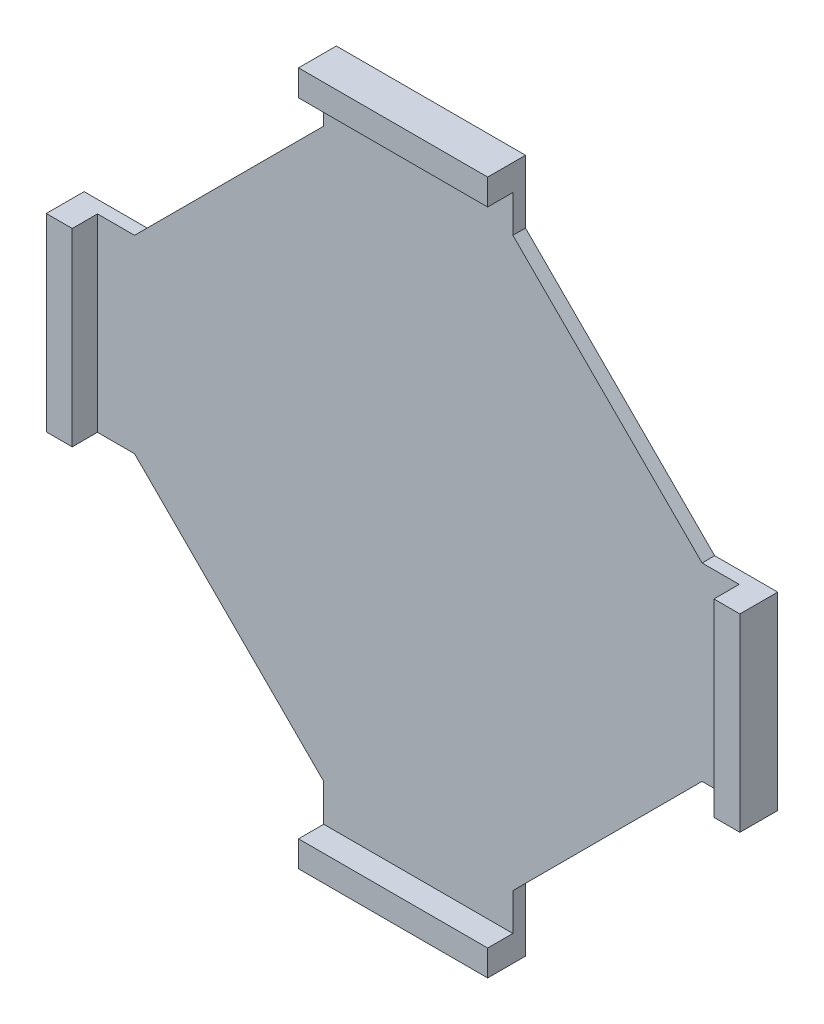
from build123d import *

# Parameters (mm, degrees)
BOSS_EXTRUDE1_DEPTH = 2.54
SKETCH2_W           = 38.1
SKETCH2_H           = 5.229692412
SKETCH2_W_2         = 5.229692412
SKETCH2_H_2         = 38.1
BOSS_EXTRUDE2_DEPTH = 5.08


with BuildPart() as part:
    # Sketch1 → Boss-Extrude1 (new body)
    with BuildSketch(Plane.XY):
        Polygon((57.15, 19.05), (69.85, 19.05), (69.85, -19.05), (57.15, -19.05), (19.05, -57.15), (19.05, -69.85), (-19.05, -69.85), (-19.05, -57.15), (-57.15, -19.05), (-69.85, -19.05), (-69.85, 19.05), (-57.15, 19.05), (-19.05, 57.15), (-19.05, 69.85), (19.05, 69.85), (19.05, 57.15), align=None)
    extrude(amount=BOSS_EXTRUDE1_DEPTH)

    # Sketch2 → Boss-Extrude2 (add)
    with BuildSketch(Plane.XY.offset(2.54)):
        with Locations((0, -67.235153794)):
            Rectangle(SKETCH2_W, SKETCH2_H)
        with Locations((-67.235153794, 0)):
            Rectangle(SKETCH2_W_2, SKETCH2_H_2)
        with Locations((0, 67.235153794)):
            Rectangle(SKETCH2_W, SKETCH2_H)
        with Locations((67.235153794, 0)):
            Rectangle(SKETCH2_W_2, SKETCH2_H_2)
    extrude(amount=BOSS_EXTRUDE2_DEPTH)


solid = part.part
